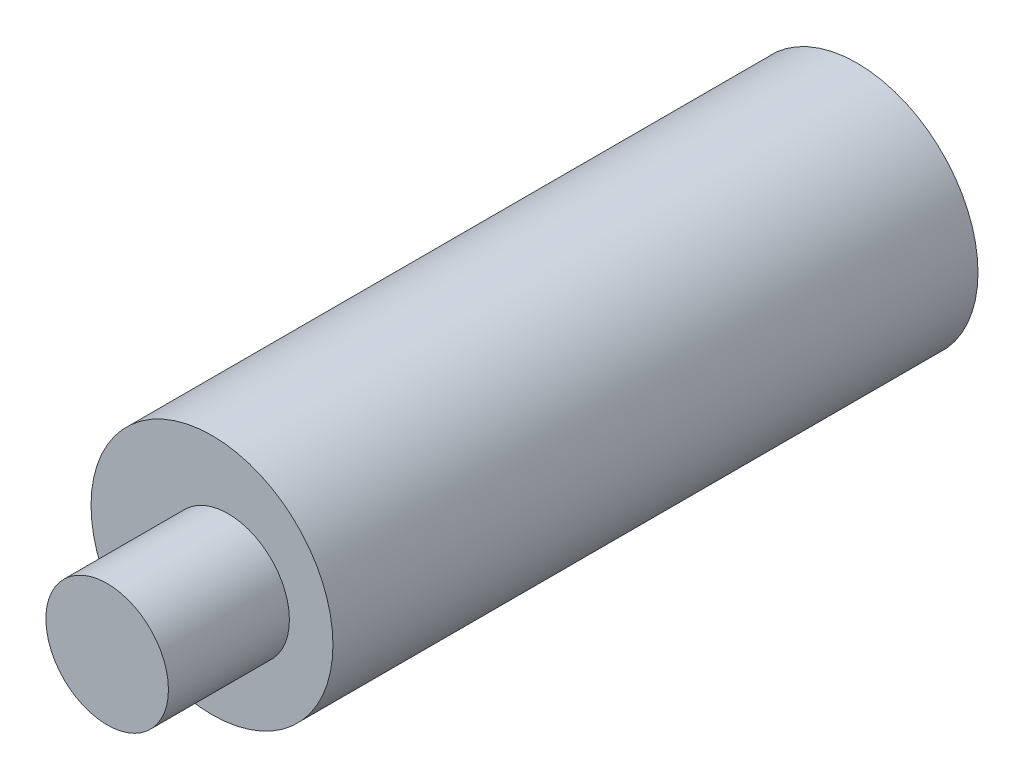
from build123d import *

# Parameters (mm, degrees)
SKETCH1_R           = 4.7625
BOSS_EXTRUDE2_DEPTH = 25.4
SKETCH4_R           = 2.413
BOSS_EXTRUDE3_DEPTH = 4.7625
SKETCH5_R           = 2.5527
CUT_EXTRUDE2_DEPTH  = 19.05


with BuildPart() as part:
    # Sketch1 → Boss-Extrude2 (new body)
    with BuildSketch(Plane.XY):
        Circle(SKETCH1_R)
    extrude(amount=BOSS_EXTRUDE2_DEPTH)

    # Sketch4 → Boss-Extrude3 (add)
    with BuildSketch(Plane.XY.offset(25.4)):
        with Locations((0.635, 0)):
            Circle(SKETCH4_R)
    extrude(amount=BOSS_EXTRUDE3_DEPTH)

    # Sketch5 → Cut-Extrude2 (cut)
    with BuildSketch(Plane(origin=(0, 0, 0), x_dir=(-1, 0, 0), z_dir=(0, 0, -1))):
        Circle(SKETCH5_R)
    extrude(amount=-CUT_EXTRUDE2_DEPTH, mode=Mode.SUBTRACT)


solid = part.part
